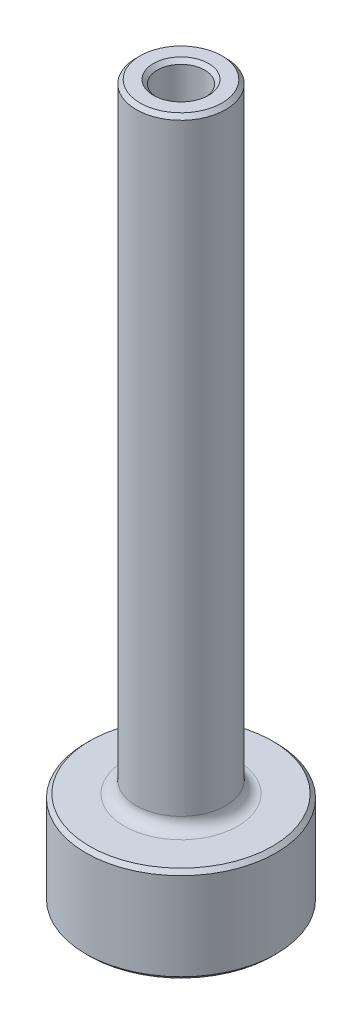
from build123d import *

# Parameters (mm, degrees)
CUT_EXTRUDE1_DEPTH = 3.175
FILLET1_R          = 0.79375
CHAMFER1_SIZE      = 0.254


with BuildPart() as part:
    # Sketch1 → Revolve1 (revolve)
    with BuildSketch(Plane.XY):
        Polygon((3.175, 0), (6.35, 0), (6.35, 6.35), (2.9845, 6.35), (2.9845, 47.625), (1.5875, 47.625), (1.5875, 3.175), (3.175, 3.175), align=None)
    revolve(axis=Axis((0, 5.569325848, 0), (0, -1, 0)))

    # Sketch2 → Cut-Extrude1 (cut)
    with BuildSketch(Plane.XZ):
        Polygon((1.833087105, 3.175), (-1.833087105, 3.175), (-3.666174209, 0), (-1.833087105, -3.175), (1.833087105, -3.175), (3.666174209, 0), align=None)
    extrude(amount=-CUT_EXTRUDE1_DEPTH, mode=Mode.SUBTRACT)

    # Fillet1
    fillet1_edges = [part.edges().sort_by_distance(p)[0] for p in [
        (0, 3.175, 3.175),
        (-2.749630657, 3.175, 1.5875),
        (-2.749630657, 3.175, -1.5875),
        (0, 3.175, -3.175),
        (2.749630657, 3.175, -1.5875),
        (2.749630657, 3.175, 1.5875),
        (-1.833087105, 1.5875, 3.175),
        (-3.666174209, 1.5875, 0),
        (-1.833087105, 1.5875, -3.175),
        (1.833087105, 1.5875, -3.175),
        (3.666174209, 1.5875, 0),
        (1.833087105, 1.5875, 3.175),
        (-2.9845, 6.35, 0),
    ]]
    fillet(fillet1_edges, radius=FILLET1_R)

    # Chamfer1
    chamfer1_edges = [part.edges().sort_by_distance(p)[0] for p in [
        (-1.5875, 3.175, 0),
        (0, 0, 3.175),
        (2.749630657, 0, 1.5875),
        (-1.5875, 47.625, 0),
        (2.749630657, 0, -1.5875),
        (0, 0, -3.175),
        (-2.9845, 47.625, 0),
        (-2.749630657, 0, -1.5875),
        (-2.749630657, 0, 1.5875),
        (-1.771690329, 0, 3.068657664),
        (1.771690329, 0, 3.068657664),
        (3.543380657, 0, 0),
        (1.771690329, 0, -3.068657664),
        (-1.771690329, 0, -3.068657664),
        (-3.543380657, 0, 0),
        (-6.35, 6.35, 0),
        (-6.35, 0, 0),
    ]]
    chamfer(chamfer1_edges, length=CHAMFER1_SIZE)


solid = part.part
